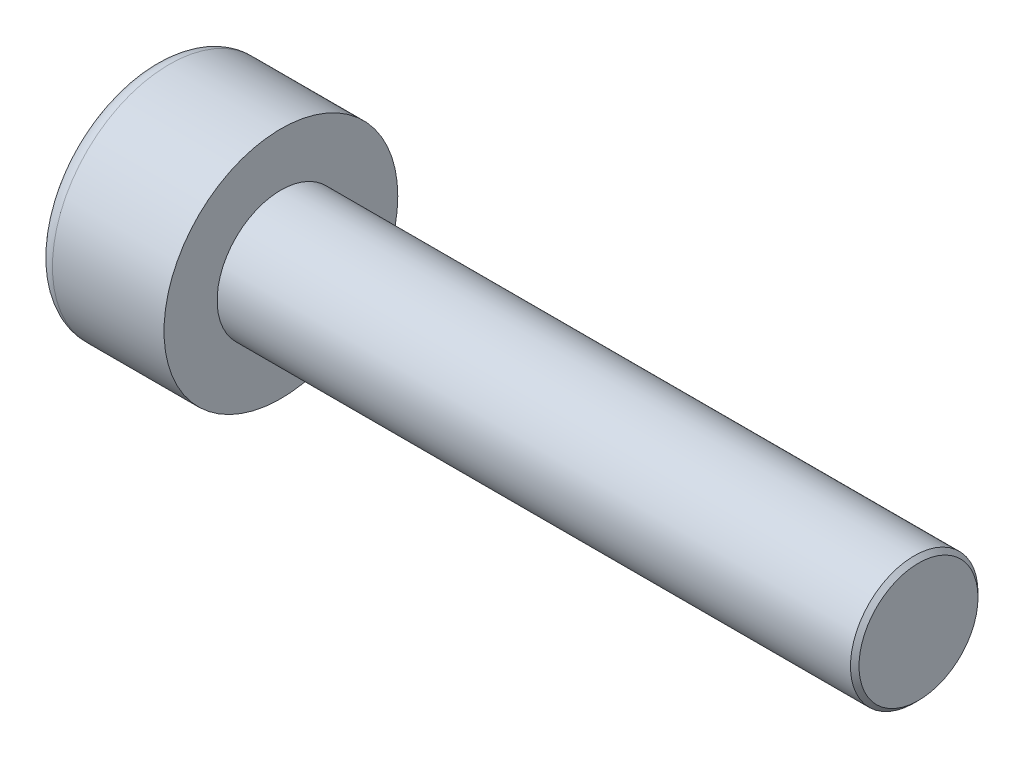
from build123d import *

# Parameters (mm, degrees)
SKETCH1_R           = 2.75
BASEHEAD_DEPTH      = 3
SKETCH2_R           = 1.5
BASEBODY_DEPTH      = 15
HEXAGONSOCKET_DEPTH = 1.3
TOPFILLET_R         = 0.375
CHAMFER1_SIZE       = 0.1


with BuildPart() as part:
    # Sketch1 → BaseHead (new body)
    with BuildSketch(Plane(origin=(0, 0, 0), x_dir=(0, 0, -1), z_dir=(1, 0, 0))):
        Circle(SKETCH1_R)
    extrude(amount=BASEHEAD_DEPTH)

    # Sketch2 → BaseBody (add)
    with BuildSketch(Plane(origin=(3, 0, 0), x_dir=(0, 0, -1), z_dir=(1, 0, 0))):
        Circle(SKETCH2_R)
    extrude(amount=BASEBODY_DEPTH)

    # Sketch3 → HexagonSocket (cut)
    with BuildSketch(Plane(origin=(0, 0, 0), x_dir=(0, 0, -1), z_dir=(1, 0, 0))):
        Polygon((1.443375673, 0), (0.721687836, 1.25), (-0.721687836, 1.25), (-1.443375673, 0), (-0.721687836, -1.25), (0.721687836, -1.25), align=None)
    extrude(amount=HEXAGONSOCKET_DEPTH, mode=Mode.SUBTRACT)

    # Sketch4 → Cut-Revolve1 (revolve, cut)
    with BuildSketch(Plane(origin=(-4.19613823, 0.75, 0), x_dir=(-1, 0, 0), z_dir=(0, 0, 1))):
        Polygon((-5.49613823, 2), (-6.217826066, 0.75), (-5.49613823, 0.75), align=None)
    revolve(axis=Axis((0.838992387, 0, 0), (-1, 0, 0)), mode=Mode.SUBTRACT)

    # TopFillet
    topfillet_edges = [part.edges().sort_by_distance(p)[0] for p in [
        (0, 0, 2.75),
    ]]
    fillet(topfillet_edges, radius=TOPFILLET_R)

    # Chamfer1
    chamfer1_edges = [part.edges().sort_by_distance(p)[0] for p in [
        (18, 0, 1.5),
    ]]
    chamfer(chamfer1_edges, length=CHAMFER1_SIZE)


solid = part.part
